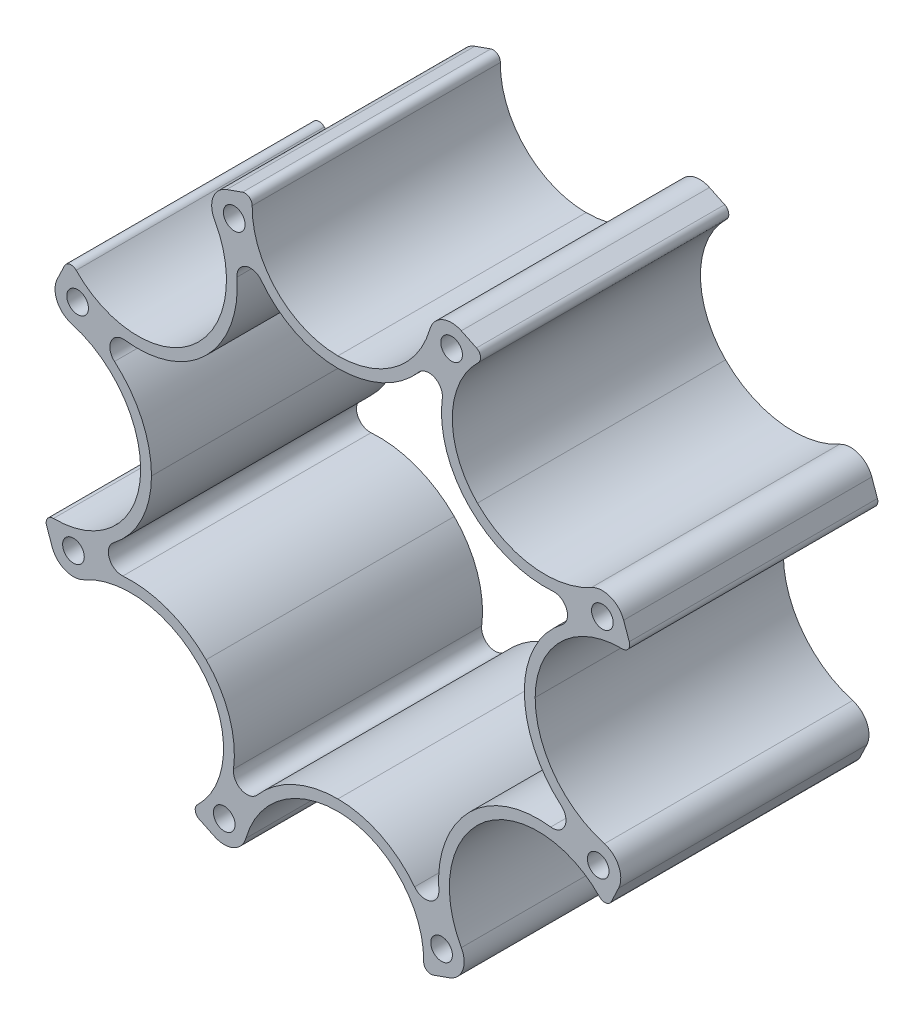
from build123d import *

# Parameters (mm, degrees)
SKETCH_1_R          = 1.2
EXTRUDE_1_DEPTH     = 27.5
CUT_EXTRUDE_1_DEPTH = 28.5


with BuildPart() as part:
    # 草图1 → 凸台-拉伸1 (new body)
    with BuildSketch(Plane.XY):
        with BuildLine():
            Line((15.356969673, 30.298929166), (13.674015522, 31.101791788))
            ThreePointArc((13.674015522, 31.101791788), (11.571454033, 31.125101256), (10.194791162, 29.535727958))
            ThreePointArc((10.194791162, 29.535727958), (6.381394442, 23.991783581), (0, 21.857511157))
            ThreePointArc((0, 21.857511157), (-6.773355282, 24.696305694), (-9.498676044, 31.516109427))
            ThreePointArc((-9.498676044, 31.516109427), (-9.831389744, 32.178886119), (-10.565560882, 32.28359567))
            Line((-10.565560882, 32.28359567), (-12.323298779, 31.661276982))
            ThreePointArc((-12.323298779, 31.661276982), (-13.826516548, 30.191023779), (-13.676107562, 28.09371949))
            ThreePointArc((-13.676107562, 28.09371949), (-12.45242558, 21.477080146), (-15.455594359, 15.455594359))
            ThreePointArc((-15.455594359, 15.455594359), (-22.252410678, 12.673439775), (-29.001832935, 15.568676449))
            ThreePointArc((-29.001832935, 15.568676449), (-29.705750942, 15.802066229), (-30.298929166, 15.356969673))
            Line((-30.298929166, 15.356969673), (-31.101791788, 13.674015522))
            ThreePointArc((-31.101791788, 13.674015522), (-31.125101256, 11.571454033), (-29.535727958, 10.194791162))
            ThreePointArc((-29.535727958, 10.194791162), (-23.991783581, 6.381394442), (-21.857511157, 0))
            ThreePointArc((-21.857511157, 0), (-24.696305694, -6.773355282), (-31.516109427, -9.498676044))
            ThreePointArc((-31.516109427, -9.498676044), (-32.178886119, -9.831389744), (-32.28359567, -10.565560882))
            Line((-32.28359567, -10.565560882), (-31.661276982, -12.323298779))
            ThreePointArc((-31.661276982, -12.323298779), (-30.191023779, -13.826516548), (-28.09371949, -13.676107562))
            ThreePointArc((-28.09371949, -13.676107562), (-21.477080146, -12.45242558), (-15.455594359, -15.455594359))
            ThreePointArc((-15.455594359, -15.455594359), (-12.673439775, -22.252410678), (-15.568676449, -29.001832935))
            ThreePointArc((-15.568676449, -29.001832935), (-15.802066229, -29.705750942), (-15.356969673, -30.298929166))
            Line((-15.356969673, -30.298929166), (-13.674015522, -31.101791788))
            ThreePointArc((-13.674015522, -31.101791788), (-11.571454033, -31.125101256), (-10.194791162, -29.535727958))
            ThreePointArc((-10.194791162, -29.535727958), (-6.381394442, -23.991783581), (0, -21.857511157))
            ThreePointArc((0, -21.857511157), (6.773355282, -24.696305694), (9.498676044, -31.516109427))
            ThreePointArc((9.498676044, -31.516109427), (9.831389744, -32.178886119), (10.565560882, -32.28359567))
            Line((10.565560882, -32.28359567), (12.323298779, -31.661276982))
            ThreePointArc((12.323298779, -31.661276982), (13.826516548, -30.191023779), (13.676107562, -28.09371949))
            ThreePointArc((13.676107562, -28.09371949), (12.45242558, -21.477080146), (15.455594359, -15.455594359))
            ThreePointArc((15.455594359, -15.455594359), (22.252410678, -12.673439775), (29.001832935, -15.568676449))
            ThreePointArc((29.001832935, -15.568676449), (29.705750942, -15.802066229), (30.298929166, -15.356969673))
            Line((30.298929166, -15.356969673), (31.101791788, -13.674015522))
            ThreePointArc((31.101791788, -13.674015522), (31.125101256, -11.571454033), (29.535727958, -10.194791162))
            ThreePointArc((29.535727958, -10.194791162), (23.991783581, -6.381394442), (21.857511157, 0))
            ThreePointArc((21.857511157, 0), (24.696305694, 6.773355282), (31.516109427, 9.498676044))
            ThreePointArc((31.516109427, 9.498676044), (32.178886119, 9.831389744), (32.28359567, 10.565560882))
            Line((32.28359567, 10.565560882), (31.661276982, 12.323298779))
            ThreePointArc((31.661276982, 12.323298779), (30.191023779, 13.826516548), (28.09371949, 13.676107562))
            ThreePointArc((28.09371949, 13.676107562), (21.477080146, 12.45242558), (15.455594359, 15.455594359))
            ThreePointArc((15.455594359, 15.455594359), (12.673439775, 22.252410678), (15.568676449, 29.001832935))
            ThreePointArc((15.568676449, 29.001832935), (15.802066229, 29.705750942), (15.356969673, 30.298929166))
        make_face()
        with Locations((12.597590691, 28.845398741)):
            Circle(SKETCH_1_R, mode=Mode.SUBTRACT)
        with Locations((29.304618859, 11.488935252)):
            Circle(SKETCH_1_R, mode=Mode.SUBTRACT)
        with Locations((28.845398741, -12.597590691)):
            Circle(SKETCH_1_R, mode=Mode.SUBTRACT)
        with Locations((11.488935252, -29.304618859)):
            Circle(SKETCH_1_R, mode=Mode.SUBTRACT)
        with Locations((-12.597590691, -28.845398741)):
            Circle(SKETCH_1_R, mode=Mode.SUBTRACT)
        with Locations((-29.304618859, -11.488935252)):
            Circle(SKETCH_1_R, mode=Mode.SUBTRACT)
        with Locations((-28.845398741, 12.597590691)):
            Circle(SKETCH_1_R, mode=Mode.SUBTRACT)
        with Locations((-11.488935252, 29.304618859)):
            Circle(SKETCH_1_R, mode=Mode.SUBTRACT)
    extrude(amount=EXTRUDE_1_DEPTH)

    # 草图2 → 切除-拉伸1 (cut, through all)
    with BuildSketch(Plane(origin=(0, 0, 0), x_dir=(-1, 0, 0), z_dir=(0, 0, -1))):
        with BuildLine():
            ThreePointArc((20.657511157, 0), (21.762964244, -4.736525047), (24.85090733, -8.494357341))
            ThreePointArc((24.85090733, -8.494357341), (25.340600313, -10.218879989), (23.827990301, -11.181059043))
            ThreePointArc((23.827990301, -11.181059043), (18.843757471, -11.888077559), (14.607066222, -14.607066222))
            ThreePointArc((14.607066222, -14.607066222), (12.039510615, -18.737968576), (11.565827414, -23.578662769))
            ThreePointArc((11.565827414, -23.578662769), (10.692670984, -25.144349657), (8.942730853, -24.755136194))
            ThreePointArc((8.942730853, -24.755136194), (4.918408433, -21.730688948), (0, -20.657511157))
            ThreePointArc((0, -20.657511157), (-4.736525047, -21.762964244), (-8.494357341, -24.85090733))
            ThreePointArc((-8.494357341, -24.85090733), (-10.218879989, -25.340600313), (-11.181059043, -23.827990301))
            ThreePointArc((-11.181059043, -23.827990301), (-11.888077559, -18.843757471), (-14.607066222, -14.607066222))
            ThreePointArc((-14.607066222, -14.607066222), (-18.737968576, -12.039510615), (-23.578662769, -11.565827414))
            ThreePointArc((-23.578662769, -11.565827414), (-25.144349657, -10.692670984), (-24.755136194, -8.942730853))
            ThreePointArc((-24.755136194, -8.942730853), (-21.730688948, -4.918408433), (-20.657511157, 0))
            ThreePointArc((-20.657511157, 0), (-21.762964244, 4.736525047), (-24.85090733, 8.494357341))
            ThreePointArc((-24.85090733, 8.494357341), (-25.340600313, 10.218879989), (-23.827990301, 11.181059043))
            ThreePointArc((-23.827990301, 11.181059043), (-18.843757471, 11.888077559), (-14.607066222, 14.607066222))
            ThreePointArc((-14.607066222, 14.607066222), (-12.039510615, 18.737968576), (-11.565827414, 23.578662769))
            ThreePointArc((-11.565827414, 23.578662769), (-10.692670984, 25.144349657), (-8.942730853, 24.755136194))
            ThreePointArc((-8.942730853, 24.755136194), (-4.918408433, 21.730688948), (0, 20.657511157))
            ThreePointArc((0, 20.657511157), (4.736525047, 21.762964244), (8.494357341, 24.85090733))
            ThreePointArc((8.494357341, 24.85090733), (10.218879989, 25.340600313), (11.181059043, 23.827990301))
            ThreePointArc((11.181059043, 23.827990301), (11.888077559, 18.843757471), (14.607066222, 14.607066222))
            ThreePointArc((14.607066222, 14.607066222), (18.737968576, 12.039510615), (23.578662769, 11.565827414))
            ThreePointArc((23.578662769, 11.565827414), (25.144349657, 10.692670984), (24.755136194, 8.942730853))
            ThreePointArc((24.755136194, 8.942730853), (21.730688948, 4.918408433), (20.657511157, 0))
        make_face()
    extrude(amount=-CUT_EXTRUDE_1_DEPTH, mode=Mode.SUBTRACT)


solid = part.part
